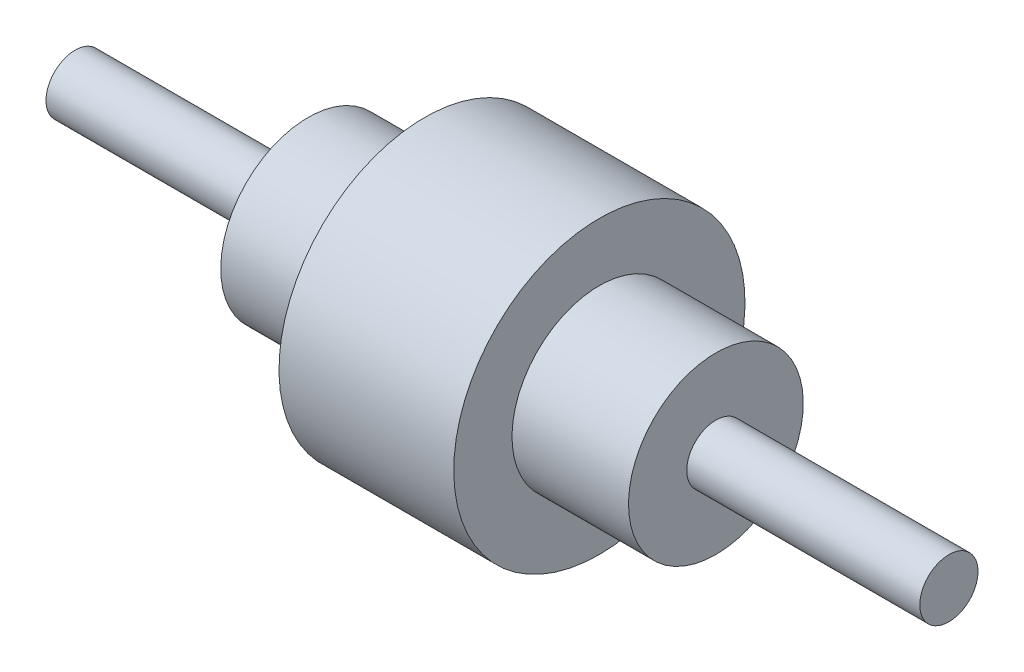
from build123d import *


with BuildPart() as part:
    # Sketch1 → Revolve6 (revolve)
    with BuildSketch(Plane.XY):
        Polygon((80, -10), (80, 0), (-220, 0), (-220, -10), (-140, -10), (-140, -30), (-100, -30), (-100, -50), (-40, -50), (-40, -30), (0, -30), (0, -10), align=None)
    revolve(axis=Axis((-337.196685694, 0, 0), (1, 0, 0)))


solid = part.part
